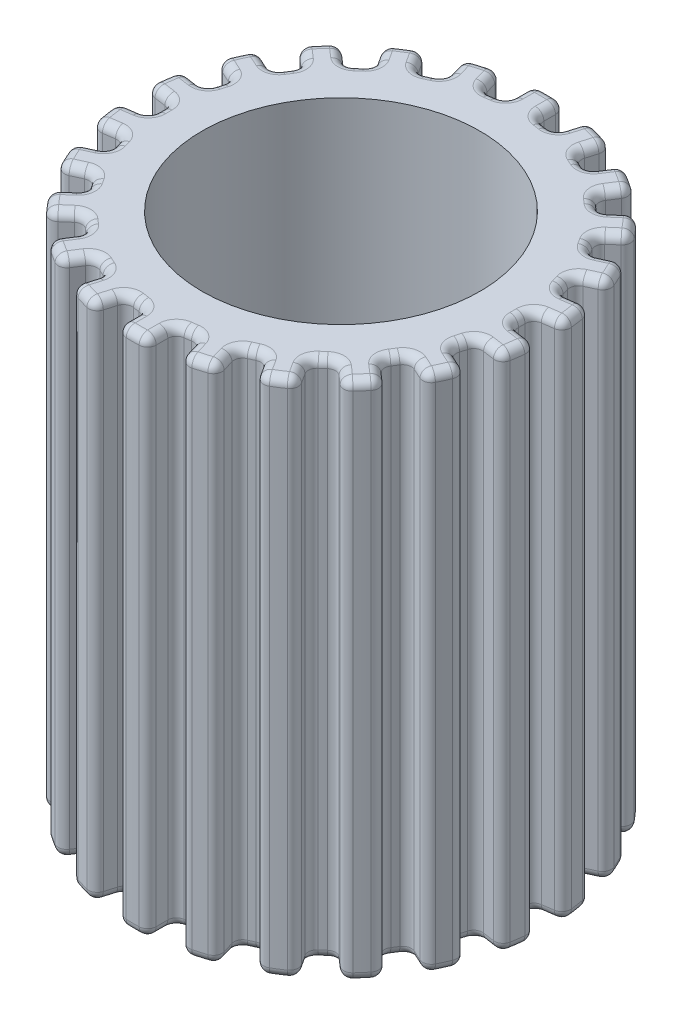
from build123d import *

# Parameters (mm, degrees)
SKETCH2_R           = 4
BOSS_EXTRUDE1_DEPTH = 15
FILLET1_R           = 0.25


with BuildPart() as part:
    # Sketch2 → Boss-Extrude1 (new body)
    with BuildSketch(Plane(origin=(0, 0, 0), x_dir=(1, 0, 0), z_dir=(0, 1, 0))):
        with BuildLine():
            Line((0.428035099, 5.984712688), (0.428035099, 5.188238822))
            ThreePointArc((0.428035099, 5.188238822), (0.740871914, 5.152877344), (1.050999119, 5.098670118))
            Line((1.050999119, 5.098670118), (1.275391738, 5.862881196))
            ThreePointArc((1.275391738, 5.862881196), (1.690395341, 5.756957842), (2.096785077, 5.62169835))
            Line((2.096785077, 5.62169835), (1.872392459, 4.857487272))
            ThreePointArc((1.872392459, 4.857487272), (2.162594705, 4.735421867), (2.444887639, 4.596037484))
            Line((2.444887639, 4.596037484), (2.875493921, 5.266073937))
            ThreePointArc((2.875493921, 5.266073937), (3.243844905, 5.047521197), (3.595665999, 4.803247446))
            Line((3.595665999, 4.803247446), (3.165059717, 4.133210992))
            ThreePointArc((3.165059717, 4.133210992), (3.409116935, 3.934330673), (3.640705902, 3.721061227))
            Line((3.640705902, 3.721061227), (4.242640687, 4.242640687))
            ThreePointArc((4.242640687, 4.242640687), (4.534497446, 3.929164404), (4.803247445, 3.595665999))
            Line((4.803247445, 3.595665999), (4.20131266, 3.074086539))
            ThreePointArc((4.20131266, 3.074086539), (4.379452785, 2.814503406), (4.541575826, 2.544626719))
            Line((4.541575826, 2.544626719), (5.266073938, 2.87549392))
            ThreePointArc((5.266073938, 2.87549392), (5.457791972, 2.492490078), (5.62169835, 2.096785078))
            Line((5.62169835, 2.096785078), (4.897200238, 1.765917877))
            ThreePointArc((4.897200238, 1.765917877), (4.994991416, 1.466661812), (5.074514286, 1.162041688))
            Line((5.074514286, 1.162041688), (5.862881196, 1.275391737))
            ThreePointArc((5.862881196, 1.275391737), (5.938928651, 0.85388903), (5.984712688, 0.428035099))
            Line((5.984712688, 0.428035099), (5.196345777, 0.31468505))
            ThreePointArc((5.196345777, 0.31468505), (5.20586555, 0), (5.196345777, -0.31468505))
            Line((5.196345777, -0.31468505), (5.984712688, -0.428035099))
            ThreePointArc((5.984712688, -0.428035099), (5.938928651, -0.85388903), (5.862881196, -1.275391737))
            Line((5.862881196, -1.275391737), (5.074514286, -1.162041688))
            ThreePointArc((5.074514286, -1.162041688), (4.994991416, -1.466661812), (4.897200238, -1.765917877))
            Line((4.897200238, -1.765917877), (5.62169835, -2.096785078))
            ThreePointArc((5.62169835, -2.096785078), (5.457791972, -2.492490078), (5.266073938, -2.87549392))
            Line((5.266073938, -2.87549392), (4.541575826, -2.544626719))
            ThreePointArc((4.541575826, -2.544626719), (4.379452785, -2.814503406), (4.20131266, -3.074086539))
            Line((4.20131266, -3.074086539), (4.803247445, -3.595665999))
            ThreePointArc((4.803247445, -3.595665999), (4.534497446, -3.929164404), (4.242640687, -4.242640687))
            Line((4.242640687, -4.242640687), (3.640705902, -3.721061227))
            ThreePointArc((3.640705902, -3.721061227), (3.409116935, -3.934330673), (3.165059717, -4.133210992))
            Line((3.165059717, -4.133210992), (3.595665999, -4.803247446))
            ThreePointArc((3.595665999, -4.803247446), (3.243844905, -5.047521197), (2.875493921, -5.266073937))
            Line((2.875493921, -5.266073937), (2.444887639, -4.596037484))
            ThreePointArc((2.444887639, -4.596037484), (2.162594705, -4.735421867), (1.872392459, -4.857487272))
            Line((1.872392459, -4.857487272), (2.096785077, -5.62169835))
            ThreePointArc((2.096785077, -5.62169835), (1.690395341, -5.756957842), (1.275391738, -5.862881196))
            Line((1.275391738, -5.862881196), (1.050999119, -5.098670118))
            ThreePointArc((1.050999119, -5.098670118), (0.740871914, -5.152877344), (0.428035099, -5.188238822))
            Line((0.428035099, -5.188238822), (0.428035099, -5.984712688))
            ThreePointArc((0.428035099, -5.984712688), (0, -6), (-0.428035099, -5.984712688))
            Line((-0.428035099, -5.984712688), (-0.428035099, -5.188238822))
            ThreePointArc((-0.428035099, -5.188238822), (-0.740871914, -5.152877344), (-1.050999119, -5.098670118))
            Line((-1.050999119, -5.098670118), (-1.275391738, -5.862881196))
            ThreePointArc((-1.275391738, -5.862881196), (-1.690395341, -5.756957842), (-2.096785077, -5.62169835))
            Line((-2.096785077, -5.62169835), (-1.872392459, -4.857487272))
            ThreePointArc((-1.872392459, -4.857487272), (-2.162594705, -4.735421867), (-2.444887639, -4.596037484))
            Line((-2.444887639, -4.596037484), (-2.875493921, -5.266073937))
            ThreePointArc((-2.875493921, -5.266073937), (-3.243844905, -5.047521197), (-3.595665999, -4.803247446))
            Line((-3.595665999, -4.803247446), (-3.165059717, -4.133210992))
            ThreePointArc((-3.165059717, -4.133210992), (-3.409116935, -3.934330673), (-3.640705902, -3.721061227))
            Line((-3.640705902, -3.721061227), (-4.242640687, -4.242640687))
            ThreePointArc((-4.242640687, -4.242640687), (-4.534497446, -3.929164404), (-4.803247445, -3.595665999))
            Line((-4.803247445, -3.595665999), (-4.20131266, -3.074086539))
            ThreePointArc((-4.20131266, -3.074086539), (-4.379452785, -2.814503406), (-4.541575826, -2.544626719))
            Line((-4.541575826, -2.544626719), (-5.266073938, -2.87549392))
            ThreePointArc((-5.266073938, -2.87549392), (-5.457791972, -2.492490078), (-5.62169835, -2.096785078))
            Line((-5.62169835, -2.096785078), (-4.897200238, -1.765917877))
            ThreePointArc((-4.897200238, -1.765917877), (-4.994991416, -1.466661812), (-5.074514286, -1.162041688))
            Line((-5.074514286, -1.162041688), (-5.862881196, -1.275391737))
            ThreePointArc((-5.862881196, -1.275391737), (-5.938928651, -0.85388903), (-5.984712688, -0.428035099))
            Line((-5.984712688, -0.428035099), (-5.196345777, -0.31468505))
            ThreePointArc((-5.196345777, -0.31468505), (-5.20586555, 0), (-5.196345777, 0.31468505))
            Line((-5.196345777, 0.31468505), (-5.984712688, 0.428035099))
            ThreePointArc((-5.984712688, 0.428035099), (-5.938928651, 0.85388903), (-5.862881196, 1.275391737))
            Line((-5.862881196, 1.275391737), (-5.074514286, 1.162041688))
            ThreePointArc((-5.074514286, 1.162041688), (-4.994991416, 1.466661812), (-4.897200238, 1.765917877))
            Line((-4.897200238, 1.765917877), (-5.62169835, 2.096785078))
            ThreePointArc((-5.62169835, 2.096785078), (-5.457791972, 2.492490078), (-5.266073938, 2.87549392))
            Line((-5.266073938, 2.87549392), (-4.541575826, 2.544626719))
            ThreePointArc((-4.541575826, 2.544626719), (-4.379452785, 2.814503406), (-4.20131266, 3.074086539))
            Line((-4.20131266, 3.074086539), (-4.803247445, 3.595665999))
            ThreePointArc((-4.803247445, 3.595665999), (-4.534497446, 3.929164404), (-4.242640687, 4.242640687))
            Line((-4.242640687, 4.242640687), (-3.640705902, 3.721061227))
            ThreePointArc((-3.640705902, 3.721061227), (-3.409116935, 3.934330673), (-3.165059717, 4.133210992))
            Line((-3.165059717, 4.133210992), (-3.595665999, 4.803247446))
            ThreePointArc((-3.595665999, 4.803247446), (-3.243844905, 5.047521197), (-2.875493921, 5.266073937))
            Line((-2.875493921, 5.266073937), (-2.444887639, 4.596037484))
            ThreePointArc((-2.444887639, 4.596037484), (-2.162594705, 4.735421867), (-1.872392459, 4.857487272))
            Line((-1.872392459, 4.857487272), (-2.096785077, 5.62169835))
            ThreePointArc((-2.096785077, 5.62169835), (-1.690395341, 5.756957842), (-1.275391738, 5.862881196))
            Line((-1.275391738, 5.862881196), (-1.050999119, 5.098670118))
            ThreePointArc((-1.050999119, 5.098670118), (-0.740871914, 5.152877344), (-0.428035099, 5.188238822))
            Line((-0.428035099, 5.188238822), (-0.428035099, 5.984712688))
            ThreePointArc((-0.428035099, 5.984712688), (0, 6), (0.428035099, 5.984712688))
        make_face()
        Circle(SKETCH2_R, mode=Mode.SUBTRACT)
    extrude(amount=BOSS_EXTRUDE1_DEPTH)

    # Fillet1
    fillet1_edges = [part.edges().sort_by_distance(p)[0] for p in [
        (-0.740871914, 15, -5.152877344),
        (-4.534497446, 15, 3.929164404),
        (-5.457791972, 0, -2.492490078),
        (-4.903824882, 0, -2.710060319),
        (-4.379452785, 0, -2.814503406),
        (-4.502280053, 0, -3.334876269),
        (-4.534497446, 0, -3.929164404),
        (-3.941673295, 0, -3.981850957),
        (-3.409116935, 0, -3.934330673),
        (-3.380362858, 0, -4.468229219),
        (-3.941673295, 15, 3.981850957),
        (-3.243844905, 0, -5.047521197),
        (-2.66019078, 0, -4.931055711),
        (-2.162594705, 0, -4.735421867),
        (-1.984588768, 0, -5.239592811),
        (-1.690395341, 0, -5.756957842),
        (-1.163195428, 0, -5.480775657),
        (-0.740871914, 0, -5.152877344),
        (-3.409116935, 15, 3.934330673),
        (-0.428035099, 0, -5.586475755),
        (0, 0, -6),
        (-3.380362858, 15, 4.468229219),
        (-3.243844905, 15, 5.047521197),
        (-2.66019078, 15, 4.931055711),
        (-2.162594705, 15, 4.735421867),
        (-1.984588768, 15, 5.239592811),
        (-1.690395341, 15, 5.756957842),
        (-1.163195428, 15, 5.480775657),
        (-1.163195428, 15, -5.480775657),
        (-0.740871914, 15, 5.152877344),
        (-0.428035099, 15, 5.586475755),
        (0.428035099, 7.5, -5.984712688),
        (0.428035099, 7.5, -5.188238822),
        (1.050999119, 7.5, -5.098670118),
        (1.275391738, 7.5, -5.862881196),
        (2.096785077, 7.5, -5.62169835),
        (1.872392459, 7.5, -4.857487272),
        (2.444887639, 7.5, -4.596037484),
        (2.875493921, 7.5, -5.266073937),
        (3.595665999, 7.5, -4.803247446),
        (3.165059717, 7.5, -4.133210992),
        (3.640705902, 7.5, -3.721061227),
        (4.242640687, 7.5, -4.242640687),
        (4.803247445, 7.5, -3.595665999),
        (4.20131266, 7.5, -3.074086539),
        (4.541575826, 7.5, -2.544626719),
        (5.266073938, 7.5, -2.87549392),
        (5.62169835, 7.5, -2.096785078),
        (4.897200238, 7.5, -1.765917877),
        (5.074514286, 7.5, -1.162041688),
        (5.862881196, 7.5, -1.275391737),
        (5.984712688, 7.5, -0.428035099),
        (5.196345777, 7.5, -0.31468505),
        (5.196345777, 7.5, 0.31468505),
        (5.984712688, 7.5, 0.428035099),
        (5.862881196, 7.5, 1.275391737),
        (5.074514286, 7.5, 1.162041688),
        (0, 15, 6),
        (4.897200238, 7.5, 1.765917877),
        (5.62169835, 7.5, 2.096785078),
        (5.266073938, 7.5, 2.87549392),
        (4.541575826, 7.5, 2.544626719),
        (4.20131266, 7.5, 3.074086539),
        (4.803247445, 7.5, 3.595665999),
        (4.242640687, 7.5, 4.242640687),
        (3.640705902, 7.5, 3.721061227),
        (3.165059717, 7.5, 4.133210992),
        (3.595665999, 7.5, 4.803247446),
        (2.875493921, 7.5, 5.266073937),
        (2.444887639, 7.5, 4.596037484),
        (1.872392459, 7.5, 4.857487272),
        (2.096785077, 7.5, 5.62169835),
        (1.275391738, 7.5, 5.862881196),
        (1.050999119, 7.5, 5.098670118),
        (0.428035099, 7.5, 5.188238822),
        (0.428035099, 7.5, 5.984712688),
        (-0.428035099, 7.5, 5.984712688),
        (-0.428035099, 7.5, 5.188238822),
        (-1.050999119, 7.5, 5.098670118),
        (-1.275391738, 7.5, 5.862881196),
        (-2.096785077, 7.5, 5.62169835),
        (-1.872392459, 7.5, 4.857487272),
        (-2.444887639, 7.5, 4.596037484),
        (-2.875493921, 7.5, 5.266073937),
        (-3.595665999, 7.5, 4.803247446),
        (-3.165059717, 7.5, 4.133210992),
        (-3.640705902, 7.5, 3.721061227),
        (-4.242640687, 7.5, 4.242640687),
        (0.428035099, 15, 5.586475755),
        (-4.803247445, 7.5, 3.595665999),
        (-4.20131266, 7.5, 3.074086539),
        (-4.541575826, 7.5, 2.544626719),
        (-5.266073938, 7.5, 2.87549392),
        (-5.62169835, 7.5, 2.096785078),
        (-4.897200238, 7.5, 1.765917877),
        (-5.074514286, 7.5, 1.162041688),
        (-5.862881196, 7.5, 1.275391737),
        (-5.984712688, 7.5, 0.428035099),
        (-5.196345777, 7.5, 0.31468505),
        (-5.196345777, 7.5, -0.31468505),
        (-5.984712688, 7.5, -0.428035099),
        (-5.862881196, 7.5, -1.275391737),
        (-5.074514286, 7.5, -1.162041688),
        (-4.897200238, 7.5, -1.765917877),
        (-5.62169835, 7.5, -2.096785078),
        (-5.266073938, 7.5, -2.87549392),
        (-4.541575826, 7.5, -2.544626719),
        (-4.20131266, 7.5, -3.074086539),
        (-4.803247445, 7.5, -3.595665999),
        (-4.242640687, 7.5, -4.242640687),
        (-3.640705902, 7.5, -3.721061227),
        (-3.165059717, 7.5, -4.133210992),
        (-3.595665999, 7.5, -4.803247446),
        (-2.875493921, 7.5, -5.266073937),
        (-2.444887639, 7.5, -4.596037484),
        (-1.872392459, 7.5, -4.857487272),
        (-2.096785077, 7.5, -5.62169835),
        (-1.275391738, 7.5, -5.862881196),
        (-1.050999119, 7.5, -5.098670118),
        (0.740871914, 15, 5.152877344),
        (-0.428035099, 7.5, -5.188238822),
        (-0.428035099, 7.5, -5.984712688),
        (1.163195428, 15, 5.480775657),
        (1.690395341, 15, 5.756957842),
        (1.984588768, 15, 5.239592811),
        (2.162594705, 15, 4.735421867),
        (2.66019078, 15, 4.931055711),
        (-1.690395341, 15, -5.756957842),
        (3.243844905, 15, 5.047521197),
        (3.380362858, 15, 4.468229219),
        (3.409116935, 15, 3.934330673),
        (3.941673295, 15, 3.981850957),
        (4.534497446, 15, 3.929164404),
        (4.502280053, 15, 3.334876269),
        (4.379452785, 15, 2.814503406),
        (4.903824882, 15, 2.710060319),
        (5.457791972, 15, 2.492490078),
        (5.259449294, 15, 1.931351477),
        (-1.984588768, 15, -5.239592811),
        (4.994991416, 15, 1.466661812),
        (5.468697741, 15, 1.218716712),
        (5.938928651, 15, 0.85388903),
        (5.590529233, 15, 0.371360075),
        (5.20586555, 15, 0),
        (5.590529233, 15, -0.371360075),
        (5.938928651, 15, -0.85388903),
        (5.468697741, 15, -1.218716712),
        (4.994991416, 15, -1.466661812),
        (5.259449294, 15, -1.931351477),
        (-2.162594705, 15, -4.735421867),
        (5.457791972, 15, -2.492490078),
        (4.903824882, 15, -2.710060319),
        (4.379452785, 15, -2.814503406),
        (4.502280053, 15, -3.334876269),
        (4.534497446, 15, -3.929164404),
        (3.941673295, 15, -3.981850957),
        (3.409116935, 15, -3.934330673),
        (3.380362858, 15, -4.468229219),
        (3.243844905, 15, -5.047521197),
        (2.66019078, 15, -4.931055711),
        (-2.66019078, 15, -4.931055711),
        (2.162594705, 15, -4.735421867),
        (1.984588768, 15, -5.239592811),
        (1.690395341, 15, -5.756957842),
        (1.163195428, 15, -5.480775657),
        (0.740871914, 15, -5.152877344),
        (0.428035099, 15, -5.586475755),
        (-3.243844905, 15, -5.047521197),
        (-3.380362858, 15, -4.468229219),
        (-3.409116935, 15, -3.934330673),
        (-3.941673295, 15, -3.981850957),
        (0, 15, -6),
        (-4.534497446, 15, -3.929164404),
        (-4.502280053, 15, -3.334876269),
        (-4.379452785, 15, -2.814503406),
        (-4.903824882, 15, -2.710060319),
        (-5.457791972, 15, -2.492490078),
        (-5.259449294, 15, -1.931351477),
        (-4.994991416, 15, -1.466661812),
        (-5.468697741, 15, -1.218716712),
        (-5.938928651, 15, -0.85388903),
        (-5.590529233, 15, -0.371360075),
        (-0.428035099, 15, -5.586475755),
        (-5.20586555, 15, 0),
        (0.428035099, 0, -5.586475755),
        (0.740871914, 0, -5.152877344),
        (1.163195428, 0, -5.480775657),
        (1.690395341, 0, -5.756957842),
        (-5.590529233, 15, 0.371360075),
        (1.984588768, 0, -5.239592811),
        (2.162594705, 0, -4.735421867),
        (2.66019078, 0, -4.931055711),
        (3.243844905, 0, -5.047521197),
        (3.380362858, 0, -4.468229219),
        (3.409116935, 0, -3.934330673),
        (3.941673295, 0, -3.981850957),
        (-5.938928651, 15, 0.85388903),
        (4.534497446, 0, -3.929164404),
        (4.502280053, 0, -3.334876269),
        (4.379452785, 0, -2.814503406),
        (4.903824882, 0, -2.710060319),
        (5.457791972, 0, -2.492490078),
        (5.259449294, 0, -1.931351477),
        (4.994991416, 0, -1.466661812),
        (5.468697741, 0, -1.218716712),
        (-5.468697741, 15, 1.218716712),
        (5.938928651, 0, -0.85388903),
        (5.590529233, 0, -0.371360075),
        (5.20586555, 0, 0),
        (5.590529233, 0, 0.371360075),
        (5.938928651, 0, 0.85388903),
        (5.468697741, 0, 1.218716712),
        (4.994991416, 0, 1.466661812),
        (-4.994991416, 15, 1.466661812),
        (5.259449294, 0, 1.931351477),
        (5.457791972, 0, 2.492490078),
        (4.903824882, 0, 2.710060319),
        (4.379452785, 0, 2.814503406),
        (4.502280053, 0, 3.334876269),
        (4.534497446, 0, 3.929164404),
        (3.941673295, 0, 3.981850957),
        (3.409116935, 0, 3.934330673),
        (-5.259449294, 15, 1.931351477),
        (3.380362858, 0, 4.468229219),
        (3.243844905, 0, 5.047521197),
        (2.66019078, 0, 4.931055711),
        (2.162594705, 0, 4.735421867),
        (1.984588768, 0, 5.239592811),
        (1.690395341, 0, 5.756957842),
        (1.163195428, 0, 5.480775657),
        (-5.457791972, 15, 2.492490078),
        (0.740871914, 0, 5.152877344),
        (0.428035099, 0, 5.586475755),
        (0, 0, 6),
        (-0.428035099, 0, 5.586475755),
        (-0.740871914, 0, 5.152877344),
        (-1.163195428, 0, 5.480775657),
        (-1.690395341, 0, 5.756957842),
        (-1.984588768, 0, 5.239592811),
        (-4.903824882, 15, 2.710060319),
        (-2.162594705, 0, 4.735421867),
        (-2.66019078, 0, 4.931055711),
        (-3.243844905, 0, 5.047521197),
        (-3.380362858, 0, 4.468229219),
        (-3.409116935, 0, 3.934330673),
        (-3.941673295, 0, 3.981850957),
        (-4.534497446, 0, 3.929164404),
        (-4.379452785, 15, 2.814503406),
        (-4.502280053, 0, 3.334876269),
        (-4.379452785, 0, 2.814503406),
        (-4.903824882, 0, 2.710060319),
        (-5.457791972, 0, 2.492490078),
        (-5.259449294, 0, 1.931351477),
        (-4.994991416, 0, 1.466661812),
        (-5.468697741, 0, 1.218716712),
        (-5.938928651, 0, 0.85388903),
        (-4.502280053, 15, 3.334876269),
        (-5.590529233, 0, 0.371360075),
        (-5.20586555, 0, 0),
        (-5.590529233, 0, -0.371360075),
        (-5.938928651, 0, -0.85388903),
        (-5.468697741, 0, -1.218716712),
        (-4.994991416, 0, -1.466661812),
        (-5.259449294, 0, -1.931351477),
    ]]
    fillet(fillet1_edges, radius=FILLET1_R)


solid = part.part
